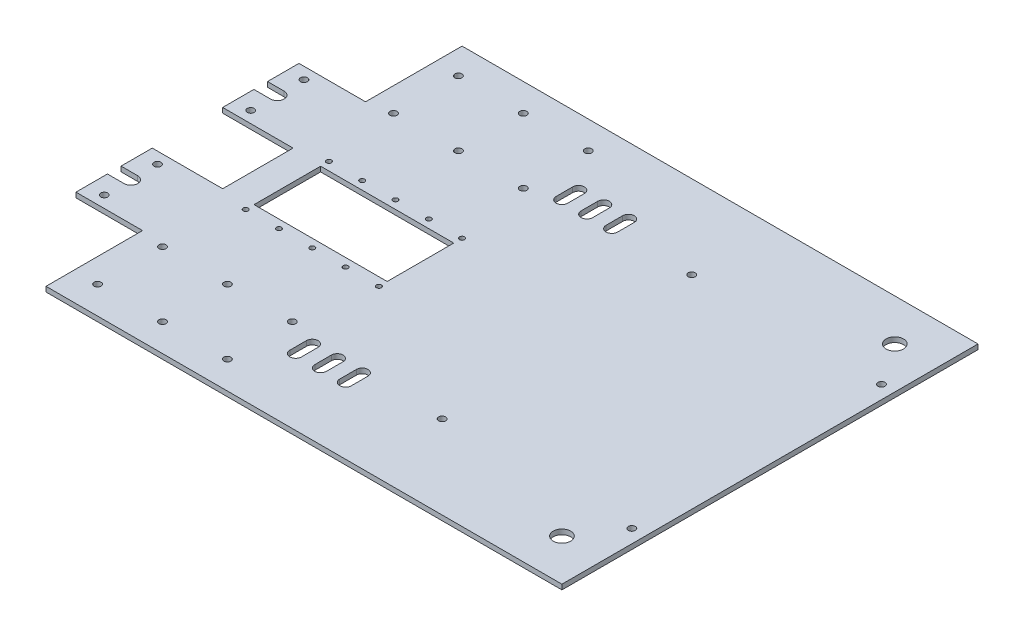
from build123d import *

# Parameters (mm, degrees)
ESQUISSE1_R             = 1.5
ESQUISSE1_R_2           = 5.25
ESQUISSE1_R_3           = 2.1
ESQUISSE1_W             = 80
ESQUISSE1_H             = 40
BOSS_EXTRU_1_DEPTH      = 3
ENL_V_MAT_EXTRU_1_REACH = 5
ESQUISSE2_R             = 2.1
ESQUISSE2_W             = 40
ESQUISSE2_H             = 58


with BuildPart() as part:
    # Esquisse1 → Boss.-Extru.1 (new body)
    with BuildSketch(Plane(origin=(0, 3, 0), x_dir=(1, 0, 0), z_dir=(0, 1, 0))):
        with BuildLine():
            Line((0, -103.85), (42.3, -103.85))
            Line((42.3, -103.85), (42.3, -146.15))
            Line((42.3, -146.15), (0, -146.15))
            Line((0, -146.15), (0, -164.900000363))
            Line((0, -164.900000363), (10.000000149, -164.900000363))
            ThreePointArc((10.000000149, -164.900000363), (14.100000149, -169.000000363), (10.000000149, -173.100000363))
            Line((10.000000149, -173.100000363), (0, -173.100000363))
            Line((0, -173.100000363), (0, -250))
            Line((0, -250), (350, -250))
            Line((350, -250), (350, 0))
            Line((350, 0), (0, 0))
            Line((0, 0), (0, -76.900000363))
            Line((0, -76.900000363), (10.000000149, -76.900000363))
            ThreePointArc((10.000000149, -76.900000363), (14.100000149, -81.000000363), (10.000000149, -85.100000363))
            Line((10.000000149, -85.100000363), (0, -85.100000363))
            Line((0, -85.100000363), (0, -103.85))
        make_face()
        with Locations((140.000001341, -150.00000149)):
            Circle(ESQUISSE1_R, mode=Mode.SUBTRACT)
        with Locations((120.000001341, -150.00000149)):
            Circle(ESQUISSE1_R, mode=Mode.SUBTRACT)
        with Locations((100.000001341, -150.00000149)):
            Circle(ESQUISSE1_R, mode=Mode.SUBTRACT)
        with Locations((80.000001341, -150.00000149)):
            Circle(ESQUISSE1_R, mode=Mode.SUBTRACT)
        with Locations((60.000001341, -150.00000149)):
            Circle(ESQUISSE1_R, mode=Mode.SUBTRACT)
        with Locations((140.000001341, -100.00000149)):
            Circle(ESQUISSE1_R, mode=Mode.SUBTRACT)
        with Locations((120.000001341, -100.00000149)):
            Circle(ESQUISSE1_R, mode=Mode.SUBTRACT)
        with Locations((100.000001341, -100.00000149)):
            Circle(ESQUISSE1_R, mode=Mode.SUBTRACT)
        with Locations((80.000001341, -100.00000149)):
            Circle(ESQUISSE1_R, mode=Mode.SUBTRACT)
        with Locations((60.000001341, -100.00000149)):
            Circle(ESQUISSE1_R, mode=Mode.SUBTRACT)
        with Locations((325, -225)):
            Circle(ESQUISSE1_R_2, mode=Mode.SUBTRACT)
        with Locations((325, -25)):
            Circle(ESQUISSE1_R_2, mode=Mode.SUBTRACT)
        with Locations((10, -97)):
            Circle(ESQUISSE1_R_3, mode=Mode.SUBTRACT)
        with Locations((10, -153)):
            Circle(ESQUISSE1_R_3, mode=Mode.SUBTRACT)
        with Locations((10, -185)):
            Circle(ESQUISSE1_R_3, mode=Mode.SUBTRACT)
        with Locations((10, -65)):
            Circle(ESQUISSE1_R_3, mode=Mode.SUBTRACT)
        with Locations((100, -125)):
            Rectangle(ESQUISSE1_W, ESQUISSE1_H, mode=Mode.SUBTRACT)
    extrude(amount=-BOSS_EXTRU_1_DEPTH)

    # Esquisse2 → Enlèv. mat.-Extru.1 (cut, up to next)
    with BuildSketch(Plane(origin=(0, 3, 0), x_dir=(1, 0, 0), z_dir=(0, 1, 0)), mode=Mode.PRIVATE) as enl_v_mat_extru_1_sk1:
        with Locations((54.4, -194.4)):
            Circle(ESQUISSE2_R)
    enl_v_mat_extru_1_tool1 = extrude(enl_v_mat_extru_1_sk1.sketch, amount=-ENL_V_MAT_EXTRU_1_REACH, mode=Mode.PRIVATE) & part.part
    add(enl_v_mat_extru_1_tool1.solids().sort_by_distance((54.4, 3, 194.4))[0], mode=Mode.SUBTRACT)
    # Esquisse2 → Enlèv. mat.-Extru.1 (cut, up to next)
    with BuildSketch(Plane(origin=(0, 3, 0), x_dir=(1, 0, 0), z_dir=(0, 1, 0)), mode=Mode.PRIVATE) as enl_v_mat_extru_1_sk2:
        with Locations((93.4, -194.4)):
            Circle(ESQUISSE2_R)
    enl_v_mat_extru_1_tool2 = extrude(enl_v_mat_extru_1_sk2.sketch, amount=-ENL_V_MAT_EXTRU_1_REACH, mode=Mode.PRIVATE) & part.part
    add(enl_v_mat_extru_1_tool2.solids().sort_by_distance((93.4, 3, 194.4))[0], mode=Mode.SUBTRACT)
    # Esquisse2 → Enlèv. mat.-Extru.1 (cut, up to next)
    with BuildSketch(Plane(origin=(0, 3, 0), x_dir=(1, 0, 0), z_dir=(0, 1, 0)), mode=Mode.PRIVATE) as enl_v_mat_extru_1_sk3:
        with Locations((93.4, -233.4)):
            Circle(ESQUISSE2_R)
    enl_v_mat_extru_1_tool3 = extrude(enl_v_mat_extru_1_sk3.sketch, amount=-ENL_V_MAT_EXTRU_1_REACH, mode=Mode.PRIVATE) & part.part
    add(enl_v_mat_extru_1_tool3.solids().sort_by_distance((93.4, 3, 233.4))[0], mode=Mode.SUBTRACT)
    # Esquisse2 → Enlèv. mat.-Extru.1 (cut, up to next)
    with BuildSketch(Plane(origin=(0, 3, 0), x_dir=(1, 0, 0), z_dir=(0, 1, 0)), mode=Mode.PRIVATE) as enl_v_mat_extru_1_sk4:
        with Locations((54.4, -233.4)):
            Circle(ESQUISSE2_R)
    enl_v_mat_extru_1_tool4 = extrude(enl_v_mat_extru_1_sk4.sketch, amount=-ENL_V_MAT_EXTRU_1_REACH, mode=Mode.PRIVATE) & part.part
    add(enl_v_mat_extru_1_tool4.solids().sort_by_distance((54.4, 3, 233.4))[0], mode=Mode.SUBTRACT)
    # Esquisse2 → Enlèv. mat.-Extru.1 (cut, up to next)
    with BuildSketch(Plane(origin=(0, 3, 0), x_dir=(1, 0, 0), z_dir=(0, 1, 0)), mode=Mode.PRIVATE) as enl_v_mat_extru_1_sk5:
        with Locations((54.4, -16.6)):
            Circle(ESQUISSE2_R)
    enl_v_mat_extru_1_tool5 = extrude(enl_v_mat_extru_1_sk5.sketch, amount=-ENL_V_MAT_EXTRU_1_REACH, mode=Mode.PRIVATE) & part.part
    add(enl_v_mat_extru_1_tool5.solids().sort_by_distance((54.4, 3, 16.6))[0], mode=Mode.SUBTRACT)
    # Esquisse2 → Enlèv. mat.-Extru.1 (cut, up to next)
    with BuildSketch(Plane(origin=(0, 3, 0), x_dir=(1, 0, 0), z_dir=(0, 1, 0)), mode=Mode.PRIVATE) as enl_v_mat_extru_1_sk6:
        with Locations((93.4, -16.6)):
            Circle(ESQUISSE2_R)
    enl_v_mat_extru_1_tool6 = extrude(enl_v_mat_extru_1_sk6.sketch, amount=-ENL_V_MAT_EXTRU_1_REACH, mode=Mode.PRIVATE) & part.part
    add(enl_v_mat_extru_1_tool6.solids().sort_by_distance((93.4, 3, 16.6))[0], mode=Mode.SUBTRACT)
    # Esquisse2 → Enlèv. mat.-Extru.1 (cut, up to next)
    with BuildSketch(Plane(origin=(0, 3, 0), x_dir=(1, 0, 0), z_dir=(0, 1, 0)), mode=Mode.PRIVATE) as enl_v_mat_extru_1_sk7:
        with Locations((93.4, -55.6)):
            Circle(ESQUISSE2_R)
    enl_v_mat_extru_1_tool7 = extrude(enl_v_mat_extru_1_sk7.sketch, amount=-ENL_V_MAT_EXTRU_1_REACH, mode=Mode.PRIVATE) & part.part
    add(enl_v_mat_extru_1_tool7.solids().sort_by_distance((93.4, 3, 55.6))[0], mode=Mode.SUBTRACT)
    # Esquisse2 → Enlèv. mat.-Extru.1 (cut, up to next)
    with BuildSketch(Plane(origin=(0, 3, 0), x_dir=(1, 0, 0), z_dir=(0, 1, 0)), mode=Mode.PRIVATE) as enl_v_mat_extru_1_sk8:
        with Locations((54.4, -55.6)):
            Circle(ESQUISSE2_R)
    enl_v_mat_extru_1_tool8 = extrude(enl_v_mat_extru_1_sk8.sketch, amount=-ENL_V_MAT_EXTRU_1_REACH, mode=Mode.PRIVATE) & part.part
    add(enl_v_mat_extru_1_tool8.solids().sort_by_distance((54.4, 3, 55.6))[0], mode=Mode.SUBTRACT)
    # Esquisse2 → Enlèv. mat.-Extru.1 (cut, up to next)
    with BuildSketch(Plane(origin=(0, 3, 0), x_dir=(1, 0, 0), z_dir=(0, 1, 0)), mode=Mode.PRIVATE) as enl_v_mat_extru_1_sk9:
        with Locations((342, -200)):
            Circle(ESQUISSE2_R)
    enl_v_mat_extru_1_tool9 = extrude(enl_v_mat_extru_1_sk9.sketch, amount=-ENL_V_MAT_EXTRU_1_REACH, mode=Mode.PRIVATE) & part.part
    add(enl_v_mat_extru_1_tool9.solids().sort_by_distance((342, 3, 200))[0], mode=Mode.SUBTRACT)
    # Esquisse2 → Enlèv. mat.-Extru.1 (cut, up to next)
    with BuildSketch(Plane(origin=(0, 3, 0), x_dir=(1, 0, 0), z_dir=(0, 1, 0)), mode=Mode.PRIVATE) as enl_v_mat_extru_1_sk10:
        with Locations((342, -50)):
            Circle(ESQUISSE2_R)
    enl_v_mat_extru_1_tool10 = extrude(enl_v_mat_extru_1_sk10.sketch, amount=-ENL_V_MAT_EXTRU_1_REACH, mode=Mode.PRIVATE) & part.part
    add(enl_v_mat_extru_1_tool10.solids().sort_by_distance((342, 3, 50))[0], mode=Mode.SUBTRACT)
    # Esquisse2 → Enlèv. mat.-Extru.1 (cut, up to next)
    with BuildSketch(Plane(origin=(0, 3, 0), x_dir=(1, 0, 0), z_dir=(0, 1, 0)), mode=Mode.PRIVATE) as enl_v_mat_extru_1_sk11:
        with Locations((228, -50)):
            Circle(ESQUISSE2_R)
    enl_v_mat_extru_1_tool11 = extrude(enl_v_mat_extru_1_sk11.sketch, amount=-ENL_V_MAT_EXTRU_1_REACH, mode=Mode.PRIVATE) & part.part
    add(enl_v_mat_extru_1_tool11.solids().sort_by_distance((228, 3, 50))[0], mode=Mode.SUBTRACT)
    # Esquisse2 → Enlèv. mat.-Extru.1 (cut, up to next)
    with BuildSketch(Plane(origin=(0, 3, 0), x_dir=(1, 0, 0), z_dir=(0, 1, 0)), mode=Mode.PRIVATE) as enl_v_mat_extru_1_sk12:
        with Locations((228, -200)):
            Circle(ESQUISSE2_R)
    enl_v_mat_extru_1_tool12 = extrude(enl_v_mat_extru_1_sk12.sketch, amount=-ENL_V_MAT_EXTRU_1_REACH, mode=Mode.PRIVATE) & part.part
    add(enl_v_mat_extru_1_tool12.solids().sort_by_distance((228, 3, 200))[0], mode=Mode.SUBTRACT)
    # Esquisse2 → Enlèv. mat.-Extru.1 (cut, up to next)
    with BuildSketch(Plane(origin=(0, 3, 0), x_dir=(1, 0, 0), z_dir=(0, 1, 0)), mode=Mode.PRIVATE) as enl_v_mat_extru_1_sk13:
        with Locations((132.4, -16.6)):
            Circle(ESQUISSE2_R)
    enl_v_mat_extru_1_tool13 = extrude(enl_v_mat_extru_1_sk13.sketch, amount=-ENL_V_MAT_EXTRU_1_REACH, mode=Mode.PRIVATE) & part.part
    add(enl_v_mat_extru_1_tool13.solids().sort_by_distance((132.4, 3, 16.6))[0], mode=Mode.SUBTRACT)
    # Esquisse2 → Enlèv. mat.-Extru.1 (cut, up to next)
    with BuildSketch(Plane(origin=(0, 3, 0), x_dir=(1, 0, 0), z_dir=(0, 1, 0)), mode=Mode.PRIVATE) as enl_v_mat_extru_1_sk14:
        with Locations((132.4, -55.6)):
            Circle(ESQUISSE2_R)
    enl_v_mat_extru_1_tool14 = extrude(enl_v_mat_extru_1_sk14.sketch, amount=-ENL_V_MAT_EXTRU_1_REACH, mode=Mode.PRIVATE) & part.part
    add(enl_v_mat_extru_1_tool14.solids().sort_by_distance((132.4, 3, 55.6))[0], mode=Mode.SUBTRACT)
    # Esquisse2 → Enlèv. mat.-Extru.1 (cut, up to next)
    with BuildSketch(Plane(origin=(0, 3, 0), x_dir=(1, 0, 0), z_dir=(0, 1, 0)), mode=Mode.PRIVATE) as enl_v_mat_extru_1_sk15:
        with Locations((132.4, -194.4)):
            Circle(ESQUISSE2_R)
    enl_v_mat_extru_1_tool15 = extrude(enl_v_mat_extru_1_sk15.sketch, amount=-ENL_V_MAT_EXTRU_1_REACH, mode=Mode.PRIVATE) & part.part
    add(enl_v_mat_extru_1_tool15.solids().sort_by_distance((132.4, 3, 194.4))[0], mode=Mode.SUBTRACT)
    # Esquisse2 → Enlèv. mat.-Extru.1 (cut, up to next)
    with BuildSketch(Plane(origin=(0, 3, 0), x_dir=(1, 0, 0), z_dir=(0, 1, 0)), mode=Mode.PRIVATE) as enl_v_mat_extru_1_sk16:
        with Locations((132.4, -233.4)):
            Circle(ESQUISSE2_R)
    enl_v_mat_extru_1_tool16 = extrude(enl_v_mat_extru_1_sk16.sketch, amount=-ENL_V_MAT_EXTRU_1_REACH, mode=Mode.PRIVATE) & part.part
    add(enl_v_mat_extru_1_tool16.solids().sort_by_distance((132.4, 3, 233.4))[0], mode=Mode.SUBTRACT)
    # Esquisse2 → Enlèv. mat.-Extru.1 (cut, up to next)
    with BuildSketch(Plane(origin=(0, 3, 0), x_dir=(1, 0, 0), z_dir=(0, 1, 0)), mode=Mode.PRIVATE) as enl_v_mat_extru_1_sk17:
        with BuildLine():
            Line((153.5, -40), (153.5, -50))
            ThreePointArc((153.5, -50), (150, -53.5), (146.5, -50))
            Line((146.5, -50), (146.5, -40))
            ThreePointArc((146.5, -40), (150, -36.5), (153.5, -40))
        make_face()
    enl_v_mat_extru_1_tool17 = extrude(enl_v_mat_extru_1_sk17.sketch, amount=-ENL_V_MAT_EXTRU_1_REACH, mode=Mode.PRIVATE) & part.part
    add(enl_v_mat_extru_1_tool17.solids().sort_by_distance((150, 3, 45))[0], mode=Mode.SUBTRACT)
    # Esquisse2 → Enlèv. mat.-Extru.1 (cut, up to next)
    with BuildSketch(Plane(origin=(0, 3, 0), x_dir=(1, 0, 0), z_dir=(0, 1, 0)), mode=Mode.PRIVATE) as enl_v_mat_extru_1_sk18:
        with BuildLine():
            Line((161.5, -40), (161.5, -50))
            ThreePointArc((161.5, -50), (165, -53.5), (168.5, -50))
            Line((168.5, -50), (168.5, -40))
            ThreePointArc((168.5, -40), (165, -36.5), (161.5, -40))
        make_face()
    enl_v_mat_extru_1_tool18 = extrude(enl_v_mat_extru_1_sk18.sketch, amount=-ENL_V_MAT_EXTRU_1_REACH, mode=Mode.PRIVATE) & part.part
    add(enl_v_mat_extru_1_tool18.solids().sort_by_distance((165, 3, 45))[0], mode=Mode.SUBTRACT)
    # Esquisse2 → Enlèv. mat.-Extru.1 (cut, up to next)
    with BuildSketch(Plane(origin=(0, 3, 0), x_dir=(1, 0, 0), z_dir=(0, 1, 0)), mode=Mode.PRIVATE) as enl_v_mat_extru_1_sk19:
        with BuildLine():
            Line((176.5, -40), (176.5, -50))
            ThreePointArc((176.5, -50), (180, -53.5), (183.5, -50))
            Line((183.5, -50), (183.5, -40))
            ThreePointArc((183.5, -40), (180, -36.5), (176.5, -40))
        make_face()
    enl_v_mat_extru_1_tool19 = extrude(enl_v_mat_extru_1_sk19.sketch, amount=-ENL_V_MAT_EXTRU_1_REACH, mode=Mode.PRIVATE) & part.part
    add(enl_v_mat_extru_1_tool19.solids().sort_by_distance((180, 3, 45))[0], mode=Mode.SUBTRACT)
    # Esquisse2 → Enlèv. mat.-Extru.1 (cut, up to next)
    with BuildSketch(Plane(origin=(0, 3, 0), x_dir=(1, 0, 0), z_dir=(0, 1, 0)), mode=Mode.PRIVATE) as enl_v_mat_extru_1_sk20:
        with BuildLine():
            Line((183.5, -210), (183.5, -200))
            ThreePointArc((183.5, -200), (180, -196.5), (176.5, -200))
            Line((176.5, -200), (176.5, -210))
            ThreePointArc((176.5, -210), (180, -213.5), (183.5, -210))
        make_face()
    enl_v_mat_extru_1_tool20 = extrude(enl_v_mat_extru_1_sk20.sketch, amount=-ENL_V_MAT_EXTRU_1_REACH, mode=Mode.PRIVATE) & part.part
    add(enl_v_mat_extru_1_tool20.solids().sort_by_distance((180, 3, 205))[0], mode=Mode.SUBTRACT)
    # Esquisse2 → Enlèv. mat.-Extru.1 (cut, up to next)
    with BuildSketch(Plane(origin=(0, 3, 0), x_dir=(1, 0, 0), z_dir=(0, 1, 0)), mode=Mode.PRIVATE) as enl_v_mat_extru_1_sk21:
        with BuildLine():
            Line((168.5, -210), (168.5, -200))
            ThreePointArc((168.5, -200), (165, -196.5), (161.5, -200))
            Line((161.5, -200), (161.5, -210))
            ThreePointArc((161.5, -210), (165, -213.5), (168.5, -210))
        make_face()
    enl_v_mat_extru_1_tool21 = extrude(enl_v_mat_extru_1_sk21.sketch, amount=-ENL_V_MAT_EXTRU_1_REACH, mode=Mode.PRIVATE) & part.part
    add(enl_v_mat_extru_1_tool21.solids().sort_by_distance((165, 3, 205))[0], mode=Mode.SUBTRACT)
    # Esquisse2 → Enlèv. mat.-Extru.1 (cut, up to next)
    with BuildSketch(Plane(origin=(0, 3, 0), x_dir=(1, 0, 0), z_dir=(0, 1, 0)), mode=Mode.PRIVATE) as enl_v_mat_extru_1_sk22:
        with BuildLine():
            Line((153.5, -210), (153.5, -200))
            ThreePointArc((153.5, -200), (150, -196.5), (146.5, -200))
            Line((146.5, -200), (146.5, -210))
            ThreePointArc((146.5, -210), (150, -213.5), (153.5, -210))
        make_face()
    enl_v_mat_extru_1_tool22 = extrude(enl_v_mat_extru_1_sk22.sketch, amount=-ENL_V_MAT_EXTRU_1_REACH, mode=Mode.PRIVATE) & part.part
    add(enl_v_mat_extru_1_tool22.solids().sort_by_distance((150, 3, 205))[0], mode=Mode.SUBTRACT)
    # Esquisse2 → Enlèv. mat.-Extru.1 (cut, up to next)
    with BuildSketch(Plane(origin=(0, 3, 0), x_dir=(1, 0, 0), z_dir=(0, 1, 0)), mode=Mode.PRIVATE) as enl_v_mat_extru_1_sk23:
        with Locations((20, -221)):
            Rectangle(ESQUISSE2_W, ESQUISSE2_H)
    enl_v_mat_extru_1_tool23 = extrude(enl_v_mat_extru_1_sk23.sketch, amount=-ENL_V_MAT_EXTRU_1_REACH, mode=Mode.PRIVATE) & part.part
    add(enl_v_mat_extru_1_tool23.solids().sort_by_distance((20, 3, 221))[0], mode=Mode.SUBTRACT)
    # Esquisse2 → Enlèv. mat.-Extru.1 (cut, up to next)
    with BuildSketch(Plane(origin=(0, 3, 0), x_dir=(1, 0, 0), z_dir=(0, 1, 0)), mode=Mode.PRIVATE) as enl_v_mat_extru_1_sk24:
        with Locations((20, -29)):
            Rectangle(ESQUISSE2_W, ESQUISSE2_H)
    enl_v_mat_extru_1_tool24 = extrude(enl_v_mat_extru_1_sk24.sketch, amount=-ENL_V_MAT_EXTRU_1_REACH, mode=Mode.PRIVATE) & part.part
    add(enl_v_mat_extru_1_tool24.solids().sort_by_distance((20, 3, 29))[0], mode=Mode.SUBTRACT)


solid = part.part
